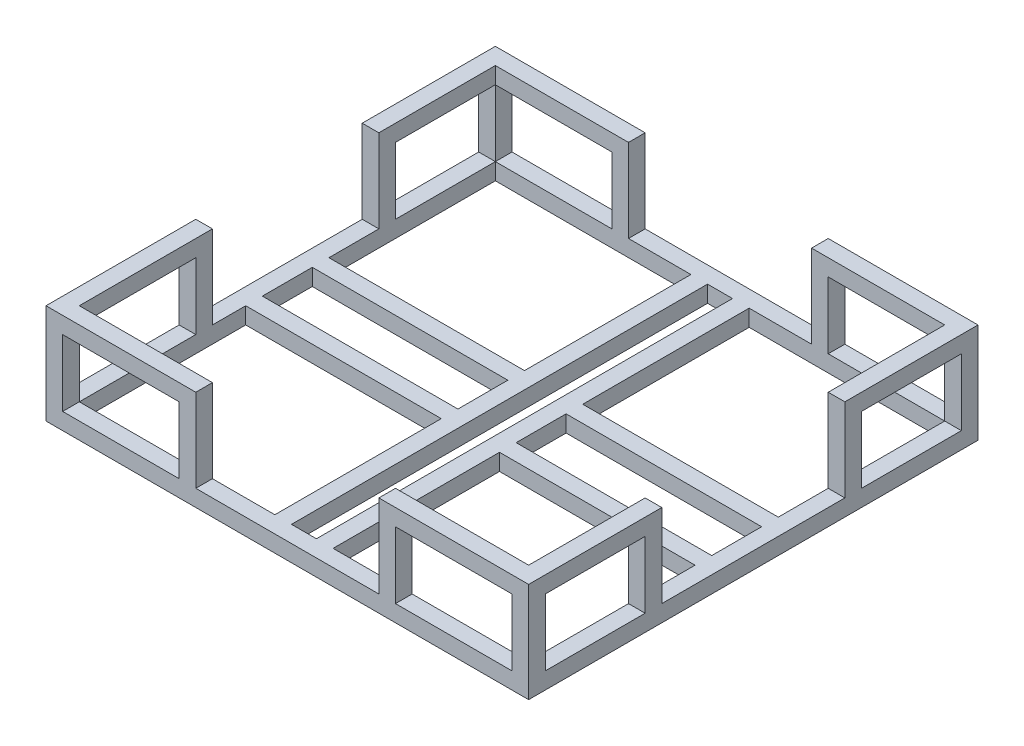
from build123d import *

# Parameters (mm, degrees)
SKETCH_2_W           = 580
SKETCH_2_H           = 540
EXTRUDE_1_DEPTH      = 20
SKETCH_3_W           = 235
SKETCH_3_H           = 200
CUT_EXTRUDE_1_DEPTH  = 21
SKETCH_4_W           = 235
SKETCH_4_H           = 200
CUT_EXTRUDE_2_DEPTH  = 21
SKETCH_5_W           = 235
SKETCH_5_H           = 200
CUT_EXTRUDE_3_DEPTH  = 21
SKETCH_6_W           = 235
SKETCH_6_H           = 200
CUT_EXTRUDE_4_DEPTH  = 21
SKETCH_7_W           = 30
SKETCH_7_H           = 500
CUT_EXTRUDE_5_DEPTH  = 21
SKETCH_8_W           = 235
SKETCH_8_H           = 60
CUT_EXTRUDE_6_DEPTH  = 21
SKETCH_9_W           = 235
SKETCH_9_H           = 60
CUT_EXTRUDE_7_DEPTH  = 21
SKETCH_10_W          = 180
SKETCH_10_H          = 20
EXTRUDE_2_DEPTH      = 100
SKETCH_11_W          = 140
SKETCH_11_H          = 80
CUT_EXTRUDE_8_DEPTH  = 21
SKETCH_12_W          = 20
SKETCH_12_H          = 140
EXTRUDE_3_DEPTH      = 100
SKETCH_13_W          = 120
SKETCH_13_H          = 80
CUT_EXTRUDE_9_DEPTH  = 21
SKETCH_14_W          = 180
SKETCH_14_H          = 20
EXTRUDE_4_DEPTH      = 100
SKETCH_15_W          = 140
SKETCH_15_H          = 80
CUT_EXTRUDE_10_DEPTH = 21
SKETCH_17_W          = 20
SKETCH_17_H          = 160
EXTRUDE_5_DEPTH      = 100
SKETCH_18_W          = 140
SKETCH_18_H          = 80
CUT_EXTRUDE_11_DEPTH = 21
SKETCH_19_W          = 180
SKETCH_19_H          = 20
EXTRUDE_6_DEPTH      = 100
SKETCH_20_W          = 140
SKETCH_20_H          = 80
CUT_EXTRUDE_12_DEPTH = 21
SKETCH_22_W          = 20
SKETCH_22_H          = 140
EXTRUDE_7_DEPTH      = 100
SKETCH_23_W          = 120
SKETCH_23_H          = 80
CUT_EXTRUDE_13_DEPTH = 581
SKETCH_24_W          = 180
SKETCH_24_H          = 20
EXTRUDE_8_DEPTH      = 100
SKETCH_25_W          = 140
SKETCH_25_H          = 80
CUT_EXTRUDE_14_DEPTH = 100
SKETCH_26_W          = 20
SKETCH_26_H          = 140
EXTRUDE_9_DEPTH      = 100
SKETCH_27_W          = 120
SKETCH_27_H          = 80
CUT_EXTRUDE_15_DEPTH = 100


with BuildPart() as part:
    # 草图2 → 凸台-拉伸1 (new body)
    with BuildSketch(Plane(origin=(0, 0, 0), x_dir=(1, 0, 0), z_dir=(0, 1, 0))):
        with Locations((17.058823529, -111.921568627)):
            Rectangle(SKETCH_2_W, SKETCH_2_H)
    extrude(amount=EXTRUDE_1_DEPTH)

    # 草图3 → 切除-拉伸1 (cut, through all)
    with BuildSketch(Plane(origin=(0, 20, 0), x_dir=(1, 0, 0), z_dir=(0, 1, 0))):
        with Locations((-135.441176471, 38.078431373)):
            Rectangle(SKETCH_3_W, SKETCH_3_H)
    extrude(amount=-CUT_EXTRUDE_1_DEPTH, mode=Mode.SUBTRACT)

    # 草图4 → 切除-拉伸2 (cut, through all)
    with BuildSketch(Plane(origin=(0, 20, 0), x_dir=(1, 0, 0), z_dir=(0, 1, 0))):
        with Locations((169.558823529, 38.078431373)):
            Rectangle(SKETCH_4_W, SKETCH_4_H)
    extrude(amount=-CUT_EXTRUDE_2_DEPTH, mode=Mode.SUBTRACT)

    # 草图5 → 切除-拉伸3 (cut, through all)
    with BuildSketch(Plane(origin=(0, 20, 0), x_dir=(1, 0, 0), z_dir=(0, 1, 0))):
        with Locations((-135.441176471, -261.921568627)):
            Rectangle(SKETCH_5_W, SKETCH_5_H)
    extrude(amount=-CUT_EXTRUDE_3_DEPTH, mode=Mode.SUBTRACT)

    # 草图6 → 切除-拉伸4 (cut, through all)
    with BuildSketch(Plane(origin=(0, 20, 0), x_dir=(1, 0, 0), z_dir=(0, 1, 0))):
        with Locations((169.558823529, -261.921568627)):
            Rectangle(SKETCH_6_W, SKETCH_6_H)
    extrude(amount=-CUT_EXTRUDE_4_DEPTH, mode=Mode.SUBTRACT)

    # 草图7 → 切除-拉伸5 (cut, through all)
    with BuildSketch(Plane(origin=(0, 20, 0), x_dir=(1, 0, 0), z_dir=(0, 1, 0))):
        with Locations((17.058823529, -111.921568627)):
            Rectangle(SKETCH_7_W, SKETCH_7_H)
    extrude(amount=-CUT_EXTRUDE_5_DEPTH, mode=Mode.SUBTRACT)

    # 草图8 → 切除-拉伸6 (cut, through all)
    with BuildSketch(Plane(origin=(0, 20, 0), x_dir=(1, 0, 0), z_dir=(0, 1, 0))):
        with Locations((-135.441176471, -111.921568627)):
            Rectangle(SKETCH_8_W, SKETCH_8_H)
    extrude(amount=-CUT_EXTRUDE_6_DEPTH, mode=Mode.SUBTRACT)

    # 草图9 → 切除-拉伸7 (cut, through all)
    with BuildSketch(Plane(origin=(0, 20, 0), x_dir=(1, 0, 0), z_dir=(0, 1, 0))):
        with Locations((169.558823529, -111.921568627)):
            Rectangle(SKETCH_9_W, SKETCH_9_H)
    extrude(amount=-CUT_EXTRUDE_7_DEPTH, mode=Mode.SUBTRACT)

    # 草图10 → 凸台-拉伸2 (add)
    with BuildSketch(Plane(origin=(0, 20, 0), x_dir=(1, 0, 0), z_dir=(0, 1, 0))):
        with Locations((-182.941176471, 148.078431373)):
            Rectangle(SKETCH_10_W, SKETCH_10_H)
    extrude(amount=EXTRUDE_2_DEPTH)

    # 草图11 → 切除-拉伸8 (cut, through all)
    with BuildSketch(Plane.XY.offset(-138.078431373)):
        with Locations((-182.941176471, 60)):
            Rectangle(SKETCH_11_W, SKETCH_11_H)
    extrude(amount=-CUT_EXTRUDE_8_DEPTH, mode=Mode.SUBTRACT)

    # 草图12 → 凸台-拉伸3 (add)
    with BuildSketch(Plane(origin=(0, 20, 0), x_dir=(1, 0, 0), z_dir=(0, 1, 0))):
        with Locations((-262.941176471, 68.078431373)):
            Rectangle(SKETCH_12_W, SKETCH_12_H)
    extrude(amount=EXTRUDE_3_DEPTH)

    # 草图13 → 切除-拉伸9 (cut, through all)
    with BuildSketch(Plane(origin=(-252.941176471, 0, 0), x_dir=(0, 0, -1), z_dir=(1, 0, 0))):
        with Locations((78.078431373, 60)):
            Rectangle(SKETCH_13_W, SKETCH_13_H)
    extrude(amount=-CUT_EXTRUDE_9_DEPTH, mode=Mode.SUBTRACT)

    # 草图14 → 凸台-拉伸4 (add)
    with BuildSketch(Plane(origin=(0, 20, 0), x_dir=(1, 0, 0), z_dir=(0, 1, 0))):
        with Locations((-182.941176471, -371.921568627)):
            Rectangle(SKETCH_14_W, SKETCH_14_H)
    extrude(amount=EXTRUDE_4_DEPTH)

    # 草图15 → 切除-拉伸10 (cut, through all)
    with BuildSketch(Plane(origin=(0, 0, 361.921568627), x_dir=(-1, 0, 0), z_dir=(0, 0, -1))):
        with Locations((182.941176471, 60)):
            Rectangle(SKETCH_15_W, SKETCH_15_H)
    extrude(amount=-CUT_EXTRUDE_10_DEPTH, mode=Mode.SUBTRACT)

    # 草图17 → 凸台-拉伸5 (add)
    with BuildSketch(Plane(origin=(0, 20, 0), x_dir=(1, 0, 0), z_dir=(0, 1, 0))):
        with Locations((-262.941176471, -281.921568627)):
            Rectangle(SKETCH_17_W, SKETCH_17_H)
    extrude(amount=EXTRUDE_5_DEPTH)

    # 草图18 → 切除-拉伸11 (cut, through all)
    with BuildSketch(Plane(origin=(-252.941176471, 0, 0), x_dir=(0, 0, -1), z_dir=(1, 0, 0))):
        with Locations((-291.921568627, 60)):
            Rectangle(SKETCH_18_W, SKETCH_18_H)
    extrude(amount=-CUT_EXTRUDE_11_DEPTH, mode=Mode.SUBTRACT)

    # 草图19 → 凸台-拉伸6 (add)
    with BuildSketch(Plane(origin=(0, 20, 0), x_dir=(1, 0, 0), z_dir=(0, 1, 0))):
        with Locations((217.058823529, 148.078431373)):
            Rectangle(SKETCH_19_W, SKETCH_19_H)
    extrude(amount=EXTRUDE_6_DEPTH)

    # 草图20 → 切除-拉伸12 (cut, through all)
    with BuildSketch(Plane.XY.offset(-138.078431373)):
        with Locations((217.058823529, 60)):
            Rectangle(SKETCH_20_W, SKETCH_20_H)
    extrude(amount=-CUT_EXTRUDE_12_DEPTH, mode=Mode.SUBTRACT)

    # 草图22 → 凸台-拉伸7 (add)
    with BuildSketch(Plane(origin=(0, 20, 0), x_dir=(1, 0, 0), z_dir=(0, 1, 0))):
        with Locations((297.058823529, 68.078431373)):
            Rectangle(SKETCH_22_W, SKETCH_22_H)
    extrude(amount=EXTRUDE_7_DEPTH)

    # 草图23 → 切除-拉伸13 (cut, through all)
    with BuildSketch(Plane(origin=(307.058823529, 0, 0), x_dir=(0, 0, -1), z_dir=(1, 0, 0))):
        with Locations((78.078431373, 60)):
            Rectangle(SKETCH_23_W, SKETCH_23_H)
    extrude(amount=-CUT_EXTRUDE_13_DEPTH, mode=Mode.SUBTRACT)

    # 草图24 → 凸台-拉伸8 (add)
    with BuildSketch(Plane(origin=(0, 20, 0), x_dir=(1, 0, 0), z_dir=(0, 1, 0))):
        with Locations((217.058823529, -371.921568627)):
            Rectangle(SKETCH_24_W, SKETCH_24_H)
    extrude(amount=EXTRUDE_8_DEPTH)

    # 草图25 → 切除-拉伸14 (cut)
    with BuildSketch(Plane(origin=(0, 0, 361.921568627), x_dir=(-1, 0, 0), z_dir=(0, 0, -1))):
        with Locations((-217.058823529, 60)):
            Rectangle(SKETCH_25_W, SKETCH_25_H)
    extrude(amount=-CUT_EXTRUDE_14_DEPTH, mode=Mode.SUBTRACT)

    # 草图26 → 凸台-拉伸9 (add)
    with BuildSketch(Plane(origin=(0, 20, 0), x_dir=(1, 0, 0), z_dir=(0, 1, 0))):
        with Locations((297.058823529, -291.921568627)):
            Rectangle(SKETCH_26_W, SKETCH_26_H)
    extrude(amount=EXTRUDE_9_DEPTH)

    # 草图27 → 切除-拉伸15 (cut)
    with BuildSketch(Plane.ZY.offset(-287.058823529)):
        with Locations((301.921568627, 60)):
            Rectangle(SKETCH_27_W, SKETCH_27_H)
    extrude(amount=-CUT_EXTRUDE_15_DEPTH, mode=Mode.SUBTRACT)


solid = part.part
